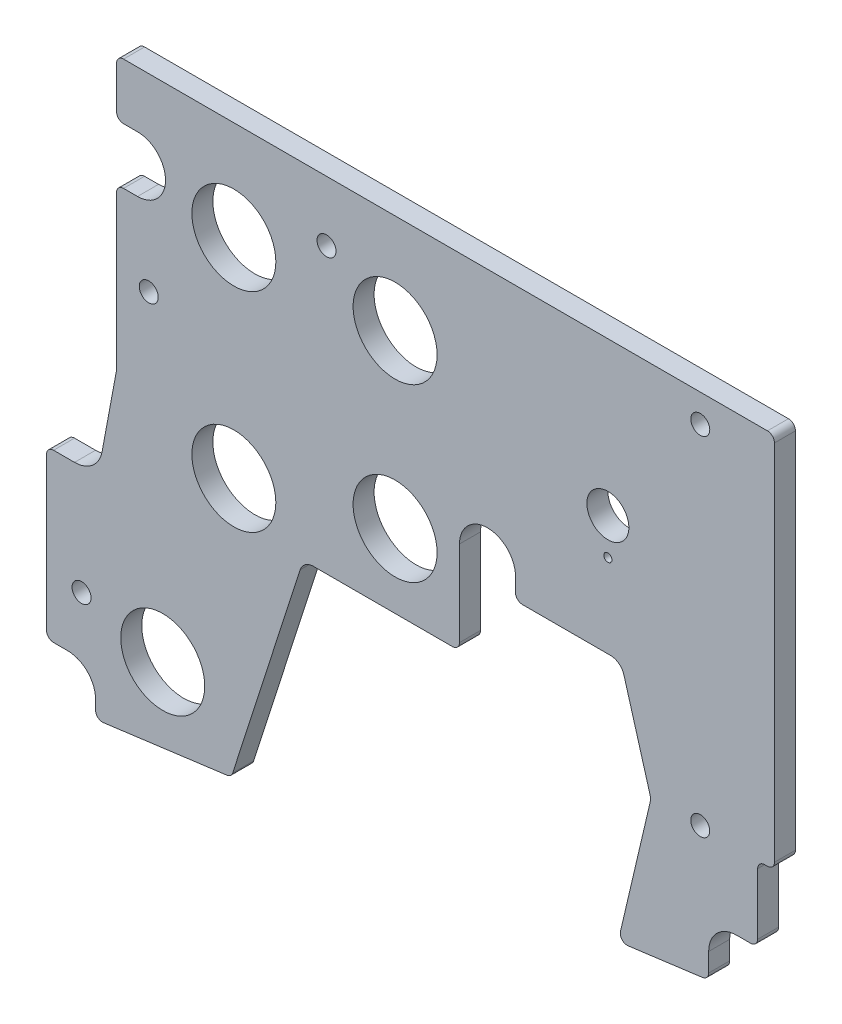
from build123d import *

# Parameters (mm, degrees)
BOSS_EXTRUDE1_DEPTH   = 4.7625
F_6_CLEARANCE_HOLE1_D = 4.3053
SKETCH5_R             = 9.525
SKETCH5_R_2           = 4.7625
CUT_EXTRUDE1_DEPTH    = 5.7625
F_0_CLEARANCE_HOLE1_D = 1.8542


with BuildPart() as part:
    # Sketch1 → Boss-Extrude1 (new body)
    with BuildSketch(Plane.XY):
        with BuildLine():
            Line((-1.58748798, -85.534500226), (-1.587499702, -3.175000338))
            ThreePointArc((-1.587499702, -3.175000338), (-2.052467807, -2.052468316), (-3.174999928, -1.587500451))
            Line((-3.174999928, -1.587500451), (-149.225000608, -1.587521198))
            ThreePointArc((-149.225000608, -1.587521198), (-150.34753241, -2.052489195), (-150.812500382, -3.175021007))
            Line((-150.812500382, -3.175021007), (-150.812501529, -12.700020556))
            ThreePointArc((-150.812501529, -12.700020556), (-150.347533612, -13.822552695), (-149.225001529, -14.287520747))
            Line((-149.225001529, -14.287520747), (-146.049997068, -14.287520747))
            ThreePointArc((-146.049997068, -14.287520747), (-139.699997068, -20.637520747), (-146.049997068, -26.987520747))
            Line((-146.049997068, -26.987520747), (-149.225013631, -26.987520747))
            ThreePointArc((-149.225013631, -26.987520747), (-150.347545646, -27.452488732), (-150.812513631, -28.575020747))
            Line((-150.812513631, -28.575020747), (-150.812513631, -63.3538504))
            ThreePointArc((-150.812513631, -63.3538504), (-150.819200601, -63.499405937), (-150.839205177, -63.643735238))
            Line((-150.839205177, -63.643735238), (-154.094231629, -81.169566712))
            ThreePointArc((-154.094231629, -81.169566712), (-156.277952028, -84.892947063), (-160.337486649, -86.360044427))
            Line((-160.337486649, -86.360044427), (-165.099987777, -86.360045103))
            ThreePointArc((-165.099987777, -86.360045103), (-166.222519646, -86.825013168), (-166.687487552, -87.947545103))
            Line((-166.687487552, -87.947545103), (-166.687487552, -122.545535149))
            ThreePointArc((-166.687487552, -122.545535149), (-166.222519567, -123.668067164), (-165.099987552, -124.133035149))
            Line((-165.099987552, -124.133035149), (-161.924987552, -124.133035149))
            ThreePointArc((-161.924987552, -124.133035149), (-157.434859491, -125.992907088), (-155.574987552, -130.483035149))
            Line((-155.574987552, -130.483035149), (-155.574987552, -132.640440399))
            ThreePointArc((-155.574987552, -132.640440399), (-155.034199033, -133.833986093), (-153.780277221, -134.214359116))
            Line((-153.780277221, -134.214359116), (-125.771097932, -130.526880708))
            ThreePointArc((-125.771097932, -130.526880708), (-124.961326394, -130.171938663), (-124.467007026, -129.438888758))
            Line((-124.467007026, -129.438888758), (-109.180488679, -81.895646464))
            ThreePointArc((-109.180488679, -81.895646464), (-108.028045294, -80.301738907), (-106.157886207, -79.6925))
            Line((-106.157886207, -79.6925), (-74.612491751, -79.6925))
            ThreePointArc((-74.612491751, -79.6925), (-73.489959736, -79.227532015), (-73.024991751, -78.105))
            Line((-73.024991751, -78.105), (-73.024991751, -58.7375))
            ThreePointArc((-73.024991751, -58.7375), (-66.674991751, -52.3875), (-60.324991751, -58.7375))
            Line((-60.324991751, -58.7375), (-60.324991751, -61.9125))
            ThreePointArc((-60.324991751, -61.9125), (-59.860023766, -63.035032015), (-58.737491751, -63.5))
            Line((-58.737491751, -63.5), (-38.786604302, -63.5))
            ThreePointArc((-38.786604302, -63.5), (-36.87752741, -64.138062787), (-35.735764486, -65.795795009))
            Line((-35.735764486, -65.795795009), (-29.83134609, -86.284116742))
            ThreePointArc((-29.83134609, -86.284116742), (-29.708193003, -87.083358908), (-29.790944576, -87.887788459))
            Line((-29.790944576, -87.887788459), (-36.522349245, -116.610151533))
            ThreePointArc((-36.522349245, -116.610151533), (-36.153591729, -118.037818788), (-34.769518371, -118.546303629))
            Line((-34.769518371, -118.546303629), (-17.8902735, -116.324110206))
            ThreePointArc((-17.8902735, -116.324110206), (-16.903937981, -115.796902916), (-16.509983709, -114.750191247))
            Line((-16.509983709, -114.750191247), (-16.509984311, -110.516938696))
            ThreePointArc((-16.509984311, -110.516938696), (-14.655116284, -106.017688645), (-10.160000902, -104.152822935))
            Line((-10.160000902, -104.152822935), (-6.9849852, -104.152822484))
            ThreePointArc((-6.9849852, -104.152822484), (-5.862453251, -103.687854339), (-5.397485425, -102.565322258))
            Line((-5.397485425, -102.565322258), (-5.397487394, -88.709500767))
            ThreePointArc((-5.397487394, -88.709500767), (-4.932519529, -87.586968646), (-3.809987507, -87.122000541))
            Line((-3.809987507, -87.122000541), (-3.17498789, -87.122000474))
            ThreePointArc((-3.17498789, -87.122000474), (-2.052455852, -86.657032363), (-1.58748798, -85.534500226))
        make_face()
    extrude(amount=BOSS_EXTRUDE1_DEPTH)

    # #6 Clearance Hole1 (through all)
    with Locations(Plane.XY.offset(4.7625)):
        with Locations((-103.187497835, -15.240014659), (-18.414998872, -7.937503157), (-143.510001128, -44.450020387), (-158.750001128, -111.125021649), (-18.414987678, -86.741003157)):
            Hole(F_6_CLEARANCE_HOLE1_D / 2)

    # Sketch5 → Cut-Extrude1 (cut, through all)
    with BuildSketch(Plane.XY.offset(4.7625)):
        with Locations((-124.205996572, -24.130021649)):
            Circle(SKETCH5_R)
        with Locations((-87.63, -24.130021649)):
            Circle(SKETCH5_R)
        with Locations((-87.63, -62.992021649)):
            Circle(SKETCH5_R)
        with Locations((-124.205996572, -71.437521424)):
            Circle(SKETCH5_R)
        with Locations((-140.334987552, -115.57)):
            Circle(SKETCH5_R)
        with Locations((-39.36999484, -36.322003157)):
            Circle(SKETCH5_R_2)
    extrude(amount=-CUT_EXTRUDE1_DEPTH, mode=Mode.SUBTRACT)

    # #0 Clearance Hole1 (through all)
    with Locations(Plane.XY.offset(6.35)):
        with Locations((-39.36999484, -44.577003157)):
            Hole(F_0_CLEARANCE_HOLE1_D / 2)


solid = part.part
